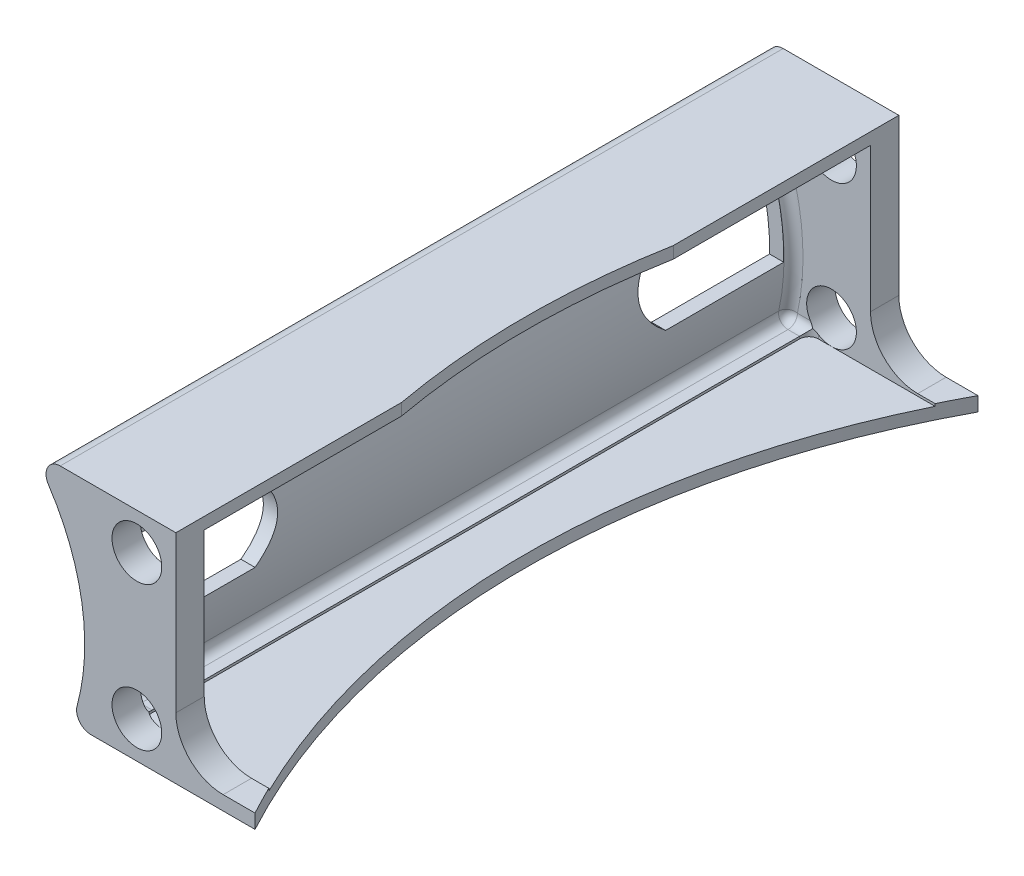
from build123d import *

# Parameters (mm, degrees)
SALIENTE_EXTRUIR1_DEPTH = 6
SALIENTE_EXTRUIR4_START = 141
SALIENTE_EXTRUIR4_DEPTH = 141
SALIENTE_EXTRUIR5_START = 6
SALIENTE_EXTRUIR5_DEPTH = 6
REDONDEO10_R            = 2
REDONDEO11_R            = 2
CROQUIS8_R              = 5.2625
CORTAR_EXTRUIR5_DEPTH   = 161
CORTAR_EXTRUIR4_DEPTH   = 157.438581273
CROQUIS10_W             = 37.37553938
CROQUIS10_H             = 2.5
SALIENTE_EXTRUIR6_DEPTH = 142
CROQUIS15_W             = 31.064336603
CROQUIS15_H             = 2.5
SALIENTE_EXTRUIR8_DEPTH = 148
CROQUIS16_R             = 1.5
CORTAR_EXTRUIR6_DEPTH   = 156
CORTAR_EXTRUIR7_DEPTH   = 64
CROQUIS19_W             = 16.749018002
CROQUIS19_H             = 43
CORTAR_EXTRUIR9_DEPTH   = 157
REDONDEO12_R            = 10


with BuildPart() as part:
    # Croquis1 → Saliente-Extruir1 (new body)
    with BuildSketch(Plane.XY):
        with BuildLine():
            Line((47.278265355, -15.875), (82.039783357, -15.875))
            Line((82.039783357, -15.875), (82.039783357, 30.125))
            Line((82.039783357, 30.125), (40.807283357, 30.125))
            ThreePointArc((40.807283357, 30.125), (38.163219926, 28.542366774), (38.308878254, 25.464285714))
            ThreePointArc((38.308878254, 25.464285714), (45.409629872, 7.346122436), (44.38367768, -12.086734694))
            ThreePointArc((44.38367768, -12.086734694), (44.89448727, -14.696428571), (47.278265355, -15.875))
        make_face()
    extrude(amount=SALIENTE_EXTRUIR1_DEPTH)

    # Croquis6 → Saliente-Extruir4 (add)
    with BuildSketch(Plane(origin=(0, 0, 0), x_dir=(-1, 0, 0), z_dir=(0, 0, -1)).offset(SALIENTE_EXTRUIR4_START)):
        with BuildLine():
            Line((-45.807283357, 27.125), (-40.807283357, 27.125))
            ThreePointArc((-40.807283357, 27.125), (-48.371127473, 7.825217377), (-47.278265355, -12.875))
            Line((-47.278265355, -12.875), (-52.278265355, -12.875))
            Line((-52.278265355, -12.875), (-52.278265355, -15.875))
            Line((-52.278265355, -15.875), (-47.278265355, -15.875))
            ThreePointArc((-47.278265355, -15.875), (-44.89448727, -14.696428571), (-44.38367768, -12.086734694))
            ThreePointArc((-44.38367768, -12.086734694), (-45.409629872, 7.346122436), (-38.308878254, 25.464285714))
            ThreePointArc((-38.308878254, 25.464285714), (-38.163219926, 28.542366774), (-40.807283357, 30.125))
            Line((-40.807283357, 30.125), (-45.807283357, 30.125))
            Line((-45.807283357, 30.125), (-45.807283357, 27.125))
        make_face()
    extrude(amount=-SALIENTE_EXTRUIR4_DEPTH)

    # Croquis7 → Saliente-Extruir5 (add)
    with BuildSketch(Plane(origin=(0, 0, -141), x_dir=(-1, 0, 0), z_dir=(0, 0, -1)).offset(SALIENTE_EXTRUIR5_START)):
        with BuildLine():
            Line((-82.039783357, 30.125), (-40.807283357, 30.125))
            ThreePointArc((-40.807283357, 30.125), (-38.163219926, 28.542366774), (-38.308878254, 25.464285714))
            ThreePointArc((-38.308878254, 25.464285714), (-45.409629872, 7.346122436), (-44.38367768, -12.086734694))
            ThreePointArc((-44.38367768, -12.086734694), (-44.89448727, -14.696428571), (-47.278265355, -15.875))
            Line((-47.278265355, -15.875), (-82.039783357, -15.875))
            Line((-82.039783357, -15.875), (-82.039783357, 30.125))
        make_face()
    extrude(amount=-SALIENTE_EXTRUIR5_DEPTH)

    # Redondeo10
    redondeo10_edges = [part.edges().sort_by_distance(p)[0] for p in [
        (43.307283357, 27.125, -141),
        (43.307283357, 27.125, 0),
        (49.778265355, -12.875, 0),
        (49.778265355, -12.875, -141),
        (40.807283357, 27.125, -70.5),
        (47.278265355, -12.875, -70.5),
        (48.371127473, 7.825217377, -141),
        (48.371127473, 7.825217377, 0),
    ]]
    fillet(redondeo10_edges, radius=REDONDEO10_R)

    # Redondeo11
    redondeo11_edges = [part.edges().sort_by_distance(p)[0] for p in [
        (45.807283357, 27.625, 0),
        (52.278265355, -13.375, 0),
        (52.278265355, -13.375, -141),
        (45.807283357, 27.625, -141),
    ]]
    fillet(redondeo11_edges, radius=REDONDEO11_R)

    # Croquis8 → Cortar-Extruir5 (cut)
    with BuildSketch(Plane(origin=(0, 0, -147), x_dir=(-1, 0, 0), z_dir=(0, 0, -1))):
        with Locations((-57.040765355, -8.1125)):
            Circle(CROQUIS8_R)
        with Locations((-57.040765355, 22.3625)):
            Circle(CROQUIS8_R)
    extrude(amount=-CORTAR_EXTRUIR5_DEPTH, mode=Mode.SUBTRACT)

    # Croquis9 → Cortar-Extruir4 (cut, through all)
    with BuildSketch(Plane(origin=(82.039783357, 0, 0), x_dir=(0, 0, -1), z_dir=(1, 0, 0))):
        with BuildLine():
            Line((138.937038998, 15.125), (138.937038998, -0.914712205))
            Line((138.937038998, -0.914712205), (113.937038998, -0.914712205))
            add(Edge.make_bspline(
                [(113.937038998, 15.125), (103.458760089, 7.301871649), (113.937038998, -0.914712205)],
                knots=[0, 0, 0, 1, 1, 1], degree=2))
            Line((113.937038998, 15.125), (138.937038998, 15.125))
        make_face()
        with BuildLine():
            Line((2.062961002, 15.125), (2.062961002, -0.914712205))
            Line((2.062961002, -0.914712205), (27.062961002, -0.914712205))
            add(Edge.make_bspline(
                [(27.062961002, 15.125), (37.541239911, 7.301871649), (27.062961002, -0.914712205)],
                knots=[0, 0, 0, 1, 1, 1], degree=2))
            Line((27.062961002, 15.125), (2.062961002, 15.125))
        make_face()
    extrude(amount=-CORTAR_EXTRUIR4_DEPTH, mode=Mode.SUBTRACT)

    # Croquis10 → Saliente-Extruir6 (add)
    with BuildSketch(Plane(origin=(0, 0, 0), x_dir=(-1, 0, 0), z_dir=(0, 0, -1))):
        with Locations((-63.352013667, 28.875)):
            Rectangle(CROQUIS10_W, CROQUIS10_H)
    extrude(amount=SALIENTE_EXTRUIR6_DEPTH)

    # Croquis15 → Saliente-Extruir8 (add)
    with BuildSketch(Plane.XY.offset(6)):
        with Locations((66.507615055, -14.625)):
            Rectangle(CROQUIS15_W, CROQUIS15_H)
    extrude(amount=-SALIENTE_EXTRUIR8_DEPTH)

    # Croquis16 → Cortar-Extruir6 (cut)
    with BuildSketch(Plane.XY.offset(6)):
        with Locations((69.039783357, 16.125)):
            Circle(CROQUIS16_R)
        with Locations((68.932075525, -1.717397604)):
            Circle(CROQUIS16_R)
    extrude(amount=-CORTAR_EXTRUIR6_DEPTH, mode=Mode.SUBTRACT)

    # Croquis18 → Cortar-Extruir7 (cut)
    with BuildSketch(Plane(origin=(0, 30.125, 0), x_dir=(1, 0, 0), z_dir=(0, 1, 0))):
        with BuildLine():
            Line((82.039783357, 147), (82.039783357, -6))
            ThreePointArc((82.039783357, -6), (62.701060719, 70.5), (82.039783357, 147))
        make_face()
    extrude(amount=-CORTAR_EXTRUIR7_DEPTH, mode=Mode.SUBTRACT)

    # Croquis19 → Cortar-Extruir9 (cut)
    with BuildSketch(Plane.XY.offset(6)):
        with Locations((73.665274356, 8.625)):
            Rectangle(CROQUIS19_W, CROQUIS19_H)
    extrude(amount=-CORTAR_EXTRUIR9_DEPTH, mode=Mode.SUBTRACT)

    # Redondeo12
    redondeo12_edges = [part.edges().sort_by_distance(p)[0] for p in [
        (65.290765355, -12.875, -144),
        (65.290765355, -12.875, 3),
    ]]
    fillet(redondeo12_edges, radius=REDONDEO12_R)


solid = part.part
